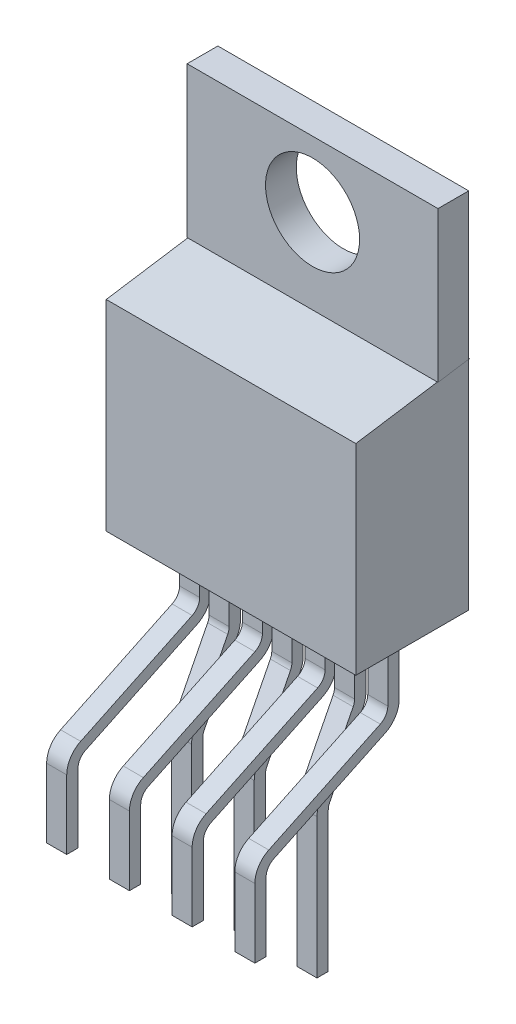
from build123d import *

# Parameters (mm, degrees)
SKETCH2_W                = 10.16
SKETCH2_H                = 4.572
BASE_EXTRUDE_DEPTH       = 14.732
CUT_EXTRUDE1_DEPTH       = 1
CUT_EXTRUDE1_DEPTH_BACK  = 11.16
CUT_EXTRUDE4_DEPTH       = 0.0254
CUT_EXTRUDE5_DEPTH       = 0.0254
CUT_EXTRUDE6_DEPTH       = 0.0254
BOSS_EXTRUDE_THIN1_DEPTH = 0.4064
LPATTERN2_COUNT          = 4
LPATTERN2_PITCH          = 2.54
BOSS_EXTRUDE_THIN2_DEPTH = 0.4064
LPATTERN3_COUNT          = 3
LPATTERN3_PITCH          = 2.54
SKETCH4_R                = 1.905
CUT_EXTRUDE2_DEPTH       = 14.732


with BuildPart() as part:
    # Sketch2 → Base-Extrude (new body)
    with BuildSketch(Plane(origin=(0, 6.35, 0), x_dir=(-1, 0, 0), z_dir=(0, 1, 0))):
        with Locations((-3.81, -5.3086)):
            Rectangle(SKETCH2_W, SKETCH2_H)
    extrude(amount=BASE_EXTRUDE_DEPTH)

    # Sketch3 → Cut-Extrude1 (cut, two sides)
    with BuildSketch(Plane.ZY.offset(1.27)) as cut_extrude1_sk:
        Polygon((-6.3246, 21.082), (-6.3246, 14.986), (-3.0226, 14.478), (-3.0226, 21.082), align=None)
    extrude(amount=CUT_EXTRUDE1_DEPTH, mode=Mode.SUBTRACT)
    extrude(cut_extrude1_sk.sketch, amount=-CUT_EXTRUDE1_DEPTH_BACK, mode=Mode.SUBTRACT)

    # Sketch5 → Cut-Extrude4 (cut)
    with BuildSketch(Plane.ZY.offset(1.27)):
        Polygon((-7.5946, 15.181384615), (-3.0226, 14.478), (-3.0226, 6.35), (-7.5946, 6.35), align=None)
    extrude(amount=-CUT_EXTRUDE4_DEPTH, mode=Mode.SUBTRACT)

    # Sketch6 → Cut-Extrude5 (cut)
    with BuildSketch(Plane(origin=(8.89, 0, 0), x_dir=(0, 0, -1), z_dir=(1, 0, 0))):
        Polygon((3.0226, 14.478), (7.5946, 15.181384615), (7.5946, 6.35), (3.0226, 6.35), align=None)
    extrude(amount=-CUT_EXTRUDE5_DEPTH, mode=Mode.SUBTRACT)

    # Sketch7 → Cut-Extrude6 (cut)
    with BuildSketch(Plane(origin=(0, 0, -7.5946), x_dir=(-1, 0, 0), z_dir=(0, 0, -1))):
        Polygon((-8.89, 21.082), (-8.89, 15.181384615), (-7.62, 15.181384615), (-7.62, 9.652), (0, 9.652), (0, 15.181384615), (1.27, 15.181384615), (1.27, 21.082), align=None)
    extrude(amount=-CUT_EXTRUDE6_DEPTH, mode=Mode.SUBTRACT)

    # Sketch9 → Boss-Extrude-Thin1 (add, symmetric)
    with BuildSketch(Plane(origin=(0, 0, 0), x_dir=(0, 0, -1), z_dir=(1, 0, 0))):
        with BuildLine():
            Line((5.1562, 6.35), (5.1562, 3.7846))
            ThreePointArc((5.1562, 3.7846), (5.07392687, 3.499994822), (4.852487561, 3.303186265))
            Line((4.852487561, 3.303186265), (0.335437388, 1.14805408))
            ThreePointArc((0.335437388, 1.14805408), (-0.075807043, 0.782552474), (-0.2286, 0.254))
            Line((-0.2286, 0.254), (-0.2286, -2.54))
            Line((-0.2286, -2.54), (0.2286, -2.54))
            Line((0.2286, -2.54), (0.2286, 0.254))
            ThreePointArc((0.2286, 0.254), (0.31087313, 0.538605178), (0.532312439, 0.735413735))
            Line((0.532312439, 0.735413735), (5.049362612, 2.89054592))
            ThreePointArc((5.049362612, 2.89054592), (5.460607043, 3.256047526), (5.6134, 3.7846))
            Line((5.6134, 3.7846), (5.6134, 6.35))
            Line((5.6134, 6.35), (5.1562, 6.35))
        make_face()
    boss_extrude_thin1 = extrude(amount=BOSS_EXTRUDE_THIN1_DEPTH, both=True)

    # LPattern2: Boss-Extrude-Thin1 ×4
    with Locations(*[(i * LPATTERN2_PITCH, 0, 0) for i in range(1, LPATTERN2_COUNT)]):
        add(boss_extrude_thin1)

    # Sketch10 → Boss-Extrude-Thin2 (add, symmetric)
    with BuildSketch(Plane(origin=(1.27, 0, 0), x_dir=(0, 0, -1), z_dir=(1, 0, 0))):
        with BuildLine():
            Line((5.08, 6.35), (5.08, 3.433803724))
            ThreePointArc((5.08, 3.433803724), (5.065314035, 3.309500424), (5.022064828, 3.192041946))
            Line((5.022064828, 3.192041946), (3.66359389, 0.520382434))
            ThreePointArc((3.66359389, 0.520382434), (3.583273936, 0.302245261), (3.556, 0.071396276))
            Line((3.556, 0.071396276), (3.556, -5.588))
            Line((3.556, -5.588), (4.0132, -5.588))
            Line((4.0132, -5.588), (4.0132, 0.071396276))
            ThreePointArc((4.0132, 0.071396276), (4.027885965, 0.195699576), (4.071135172, 0.313158054))
            Line((4.071135172, 0.313158054), (5.42960611, 2.984817566))
            ThreePointArc((5.42960611, 2.984817566), (5.509926064, 3.202954739), (5.5372, 3.433803724))
            Line((5.5372, 3.433803724), (5.5372, 6.35))
            Line((5.5372, 6.35), (5.08, 6.35))
        make_face()
    boss_extrude_thin2 = extrude(amount=BOSS_EXTRUDE_THIN2_DEPTH, both=True)

    # LPattern3: Boss-Extrude-Thin2 ×3
    with Locations(*[(i * LPATTERN3_PITCH, 0, 0) for i in range(1, LPATTERN3_COUNT)]):
        add(boss_extrude_thin2)

    # Sketch4 → Cut-Extrude2 (cut)
    with BuildSketch(Plane.XY.offset(-6.3246)):
        with Locations((3.81, 18.415)):
            Circle(SKETCH4_R)
    extrude(amount=-CUT_EXTRUDE2_DEPTH, mode=Mode.SUBTRACT)


solid = part.part
